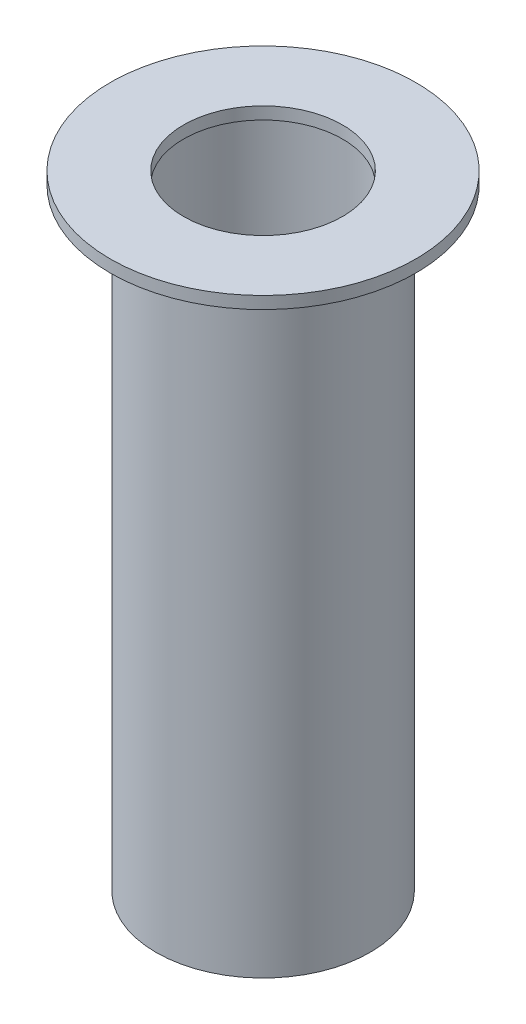
from build123d import *

# Parameters (mm, degrees)
SKETCH1_R           = 7
SKETCH1_R_2         = 6.2
BOSS_EXTRUDE1_DEPTH = 20
SKETCH4_R           = 10
SKETCH4_R_2         = 5.2
BOSS_EXTRUDE3_DEPTH = 0.8


with BuildPart() as part:
    # Sketch1 → Boss-Extrude1 (new body, symmetric)
    with BuildSketch(Plane(origin=(0, 0, 0), x_dir=(1, 0, 0), z_dir=(0, 1, 0))):
        Circle(SKETCH1_R)
        Circle(SKETCH1_R_2, mode=Mode.SUBTRACT)
    extrude(amount=BOSS_EXTRUDE1_DEPTH, both=True)

    # Sketch4 → Boss-Extrude3 (add)
    with BuildSketch(Plane(origin=(0, 20, 0), x_dir=(1, 0, 0), z_dir=(0, 1, 0))):
        Circle(SKETCH4_R)
        Circle(SKETCH4_R_2, mode=Mode.SUBTRACT)
    extrude(amount=BOSS_EXTRUDE3_DEPTH)


solid = part.part
